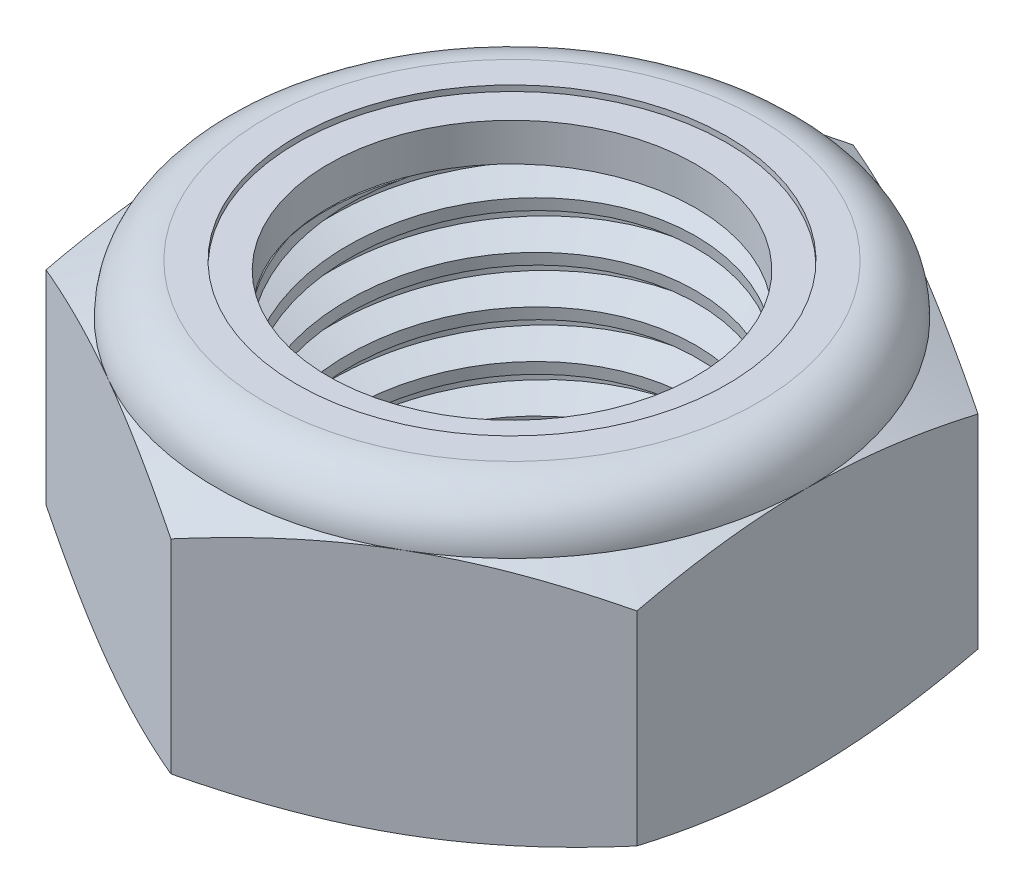
from build123d import *

# Parameters (mm, degrees)
EXTRUDE1_DEPTH      = 7.9375
SKETCH2_W           = 5.55625
SKETCH2_H           = 7.9375
LPATTERN1_COUNT     = 6
LPATTERN1_PITCH     = 1.27
LPATTERN1_COL_COUNT = 2
LPATTERN1_COL_PITCH = 1.27


with BuildPart() as part:
    # Sketch1 → Extrude1 (new body)
    with BuildSketch(Plane(origin=(0, 0, 0), x_dir=(1, 0, 0), z_dir=(0, 1, 0))):
        Polygon((0, 9.165435523), (-7.9375, 4.582717762), (-7.9375, -4.582717762), (0, -9.165435523), (7.9375, -4.582717762), (7.9375, 4.582717762), align=None)
    extrude(amount=EXTRUDE1_DEPTH)

    # Sketch4 → Cut-Revolve2 (revolve, cut)
    with BuildSketch(Plane(origin=(0, 0, 0), x_dir=(0, 0, -1), z_dir=(1, 0, 0))):
        Polygon((0, 7.9375), (5.55625, 7.9375), (4.936377351, 7.648448637), (4.936377351, 0.289051363), (5.55625, 0), (0, 0), align=None)
    revolve(axis=Axis((0, 7.9375, 0), (0, 1, 0)), mode=Mode.SUBTRACT)


with BuildPart() as body_2:
    # Sketch2 → Revolve1 (revolve)
    with BuildSketch(Plane(origin=(0, 0, 0), x_dir=(0, 0, -1), z_dir=(1, 0, 0))):
        with Locations((2.778125, 3.96875)):
            Rectangle(SKETCH2_W, SKETCH2_H)
    revolve(axis=Axis((0, -5.55625, 0), (0, 1, 0)))

    # Sketch3 → Cut-Revolve1 (revolve, cut)
    with BuildSketch(Plane(origin=(0, 0, 0), x_dir=(0, 0, -1), z_dir=(1, 0, 0))):
        Polygon((5.574275521, 7.779776688), (5.700454171, 6.675713506), (4.972428394, 6.991968988), (4.936377351, 7.307415612), align=None)
    cut_revolve1 = revolve(axis=Axis((0, 7.9375, 0.154745734), (0, -0.993532673, -0.113546591)), mode=Mode.SUBTRACT)

    # LPattern1: Cut-Revolve1 ×6
    with Locations(*[(0, -i * LPATTERN1_PITCH, 0) for i in range(1, LPATTERN1_COUNT)]):
        add(cut_revolve1, mode=Mode.SUBTRACT)

    # LPattern1 col: Cut-Revolve1 ×2
    with Locations(*[(0, i * LPATTERN1_COL_PITCH, 0) for i in range(1, LPATTERN1_COL_COUNT)]):
        add(cut_revolve1, mode=Mode.SUBTRACT)


with BuildPart() as part_1:
    add(part.part)

    # Combine1: cut body 2
    add(body_2.part, mode=Mode.SUBTRACT)

    # Sketch5 → Cut-Revolve3 (revolve, cut)
    with BuildSketch(Plane(origin=(0, 0, 0), x_dir=(0, 0, -1), z_dir=(1, 0, 0))):
        with BuildLine():
            Line((0, 0), (7.9375, 0))
            Line((7.9375, 0), (9.165435523, 0.572595738))
            Line((9.165435523, 0.572595738), (9.165435523, 6.041987595))
            Line((9.165435523, 6.041987595), (7.9375, 6.614583333))
            ThreePointArc((7.9375, 6.614583333), (7.550026679, 7.550026679), (6.614583333, 7.9375))
            Line((6.614583333, 7.9375), (6.614583333, 9.2075))
            Line((6.614583333, 9.2075), (10.435435523, 9.2075))
            Line((10.435435523, 9.2075), (10.435435523, -1.27))
            Line((10.435435523, -1.27), (0, -1.27))
            Line((0, -1.27), (0, 0))
        make_face()
    revolve(axis=Axis((0, 0, 0), (0, 1, 0)), mode=Mode.SUBTRACT)

    # Sketch6 → Cut-Revolve4 (revolve, cut)
    with BuildSketch(Plane(origin=(0, 0, 0), x_dir=(0, 0, -1), z_dir=(1, 0, 0))):
        with BuildLine():
            Line((0, 6.614583333), (7.7851, 6.614583333))
            ThreePointArc((7.7851, 6.614583333), (7.442263606, 7.442263606), (6.614583333, 7.7851))
            Line((6.614583333, 7.7851), (5.775480342, 7.7851))
            Line((5.775480342, 7.7851), (5.775480342, 9.2075))
            Line((5.775480342, 9.2075), (0, 9.2075))
            Line((0, 9.2075), (0, 6.614583333))
        make_face()
    revolve(axis=Axis((0, 9.2075, 0), (0, 1, 0)), mode=Mode.SUBTRACT)


with BuildPart() as body_2_2:
    # Sketch7 → Revolve2 (revolve)
    with BuildSketch(Plane(origin=(0, 0, 0), x_dir=(0, 0, -1), z_dir=(1, 0, 0))):
        with BuildLine():
            Line((4.936377351, 6.690783333), (7.706243778, 6.690783333))
            ThreePointArc((7.706243778, 6.690783333), (7.360955237, 7.4148695), (6.614583333, 7.7089))
            Line((6.614583333, 7.7089), (4.936377351, 7.7089))
            Line((4.936377351, 7.7089), (4.936377351, 6.690783333))
        make_face()
    revolve(axis=Axis((0, 6.690783333, 0), (0, 1, 0)))


solid = Compound([part_1.part, body_2_2.part])
